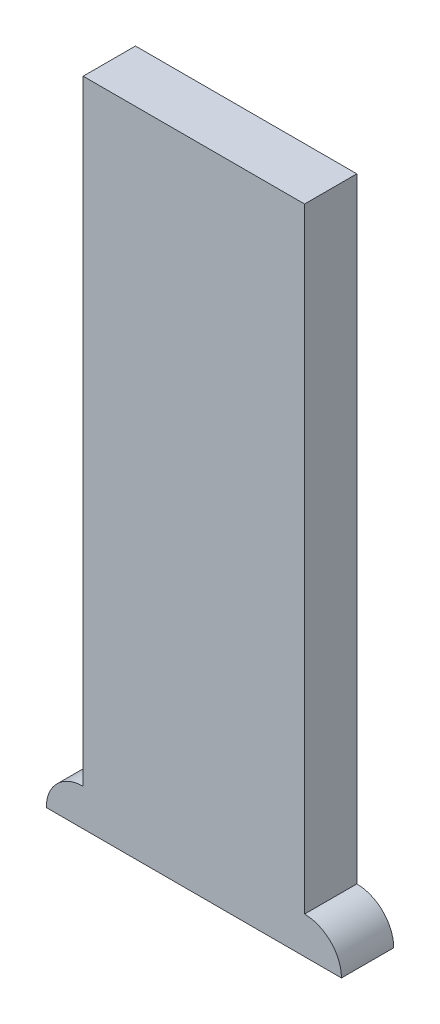
from build123d import *

# Parameters (mm, degrees)
BOSS_EXTRUDE1_DEPTH                             = 8.5
SKETCH5_W                                       = 36
SKETCH5_H                                       = 8.5
BOSS_EXTRUDE2_DEPTH                             = 100
CSK_FOR_M3_FLAT_HEAD_MACHINE_SCREW2_D           = 3.4
CSK_FOR_M3_FLAT_HEAD_MACHINE_SCREW2_DEPTH       = 10
CSK_FOR_M3_FLAT_HEAD_MACHINE_SCREW2_CSINK_D     = 6.3
CSK_FOR_M3_FLAT_HEAD_MACHINE_SCREW2_CSINK_ANGLE = 90
CSK_FOR_M3_FLAT_HEAD_MACHINE_SCREW2_TIP         = 1.021463052
LPATTERN1_COUNT                                 = 12
LPATTERN1_PITCH                                 = 8


with BuildPart() as part:
    # Sketch1 → Boss-Extrude1 (new body)
    with BuildSketch(Plane.XY):
        with BuildLine():
            Line((0, 0), (48, 0))
            ThreePointArc((48, 0), (46.242640687, 4.242640687), (42, 6))
            Line((42, 6), (6, 6))
            ThreePointArc((6, 6), (1.757359313, 4.242640687), (0, 0))
        make_face()
    extrude(amount=BOSS_EXTRUDE1_DEPTH)

    # Sketch5 → Boss-Extrude2 (add)
    with BuildSketch(Plane(origin=(0, 6, 0), x_dir=(1, 0, 0), z_dir=(0, 1, 0))):
        with Locations((24, -4.25)):
            Rectangle(SKETCH5_W, SKETCH5_H)
    extrude(amount=BOSS_EXTRUDE2_DEPTH)

    # Sketch14 → Ø3.0mm Dowel Hole3 (revolve, cut)
    with BuildSketch(Plane(origin=(37, 101, 0), x_dir=(0, 1, 0), z_dir=(1, 0, 0))):
        Polygon((0, 0), (0, 5.901290929), (1.5, 5), (1.5, 0), align=None)
    f_3_0mm_dowel_hole3 = revolve(axis=Axis((37, 101, -6.35), (0, 0, 1)), mode=Mode.SUBTRACT)

    # CSK for M3 Flat Head Machine Screw2
    with Locations(Plane(origin=(0, 0, 0), x_dir=(-1, 0, 0), z_dir=(0, -1, 0))):
        with Locations((-39, -4.25), (-9, -4.25)):
            CounterSinkHole(CSK_FOR_M3_FLAT_HEAD_MACHINE_SCREW2_D / 2, CSK_FOR_M3_FLAT_HEAD_MACHINE_SCREW2_CSINK_D / 2, depth=CSK_FOR_M3_FLAT_HEAD_MACHINE_SCREW2_DEPTH, counter_sink_angle=CSK_FOR_M3_FLAT_HEAD_MACHINE_SCREW2_CSINK_ANGLE)
            with Locations((0, 0, -(CSK_FOR_M3_FLAT_HEAD_MACHINE_SCREW2_DEPTH + CSK_FOR_M3_FLAT_HEAD_MACHINE_SCREW2_TIP / 2))):  # 118° drill point
                Cone(0, CSK_FOR_M3_FLAT_HEAD_MACHINE_SCREW2_D / 2, CSK_FOR_M3_FLAT_HEAD_MACHINE_SCREW2_TIP, mode=Mode.SUBTRACT)

    # Mirror1: Ø3.0mm Dowel Hole3 across plane
    add(f_3_0mm_dowel_hole3.mirror(Plane(origin=(24, 0, 0), x_dir=(0, 0, 1), z_dir=(1, 0, 0))), mode=Mode.SUBTRACT)

    # LPattern1: Ø3.0mm Dowel Hole3 ×12
    with Locations(*[(0, -i * LPATTERN1_PITCH, 0) for i in range(1, LPATTERN1_COUNT)]):
        add(f_3_0mm_dowel_hole3, mode=Mode.SUBTRACT)

    # LPattern1 copy 1 sketch → LPattern1 copy 1 (revolve, cut)
    with BuildSketch(Plane(origin=(11, 93, 0), x_dir=(0, 1, 0), z_dir=(-1, 0, 0))):
        Polygon((0, 0), (0, -5.901290929), (1.5, -5), (1.5, 0), align=None)
    revolve(axis=Axis((11, 93, -6.35), (0, 0, -1)), mode=Mode.SUBTRACT)

    # LPattern1 copy 2 sketch → LPattern1 copy 2 (revolve, cut)
    with BuildSketch(Plane(origin=(11, 85, 0), x_dir=(0, 1, 0), z_dir=(-1, 0, 0))):
        Polygon((0, 0), (0, -5.901290929), (1.5, -5), (1.5, 0), align=None)
    revolve(axis=Axis((11, 85, -6.35), (0, 0, -1)), mode=Mode.SUBTRACT)

    # LPattern1 copy 3 sketch → LPattern1 copy 3 (revolve, cut)
    with BuildSketch(Plane(origin=(11, 77, 0), x_dir=(0, 1, 0), z_dir=(-1, 0, 0))):
        Polygon((0, 0), (0, -5.901290929), (1.5, -5), (1.5, 0), align=None)
    revolve(axis=Axis((11, 77, -6.35), (0, 0, -1)), mode=Mode.SUBTRACT)

    # LPattern1 copy 4 sketch → LPattern1 copy 4 (revolve, cut)
    with BuildSketch(Plane(origin=(11, 69, 0), x_dir=(0, 1, 0), z_dir=(-1, 0, 0))):
        Polygon((0, 0), (0, -5.901290929), (1.5, -5), (1.5, 0), align=None)
    revolve(axis=Axis((11, 69, -6.35), (0, 0, -1)), mode=Mode.SUBTRACT)

    # LPattern1 copy 5 sketch → LPattern1 copy 5 (revolve, cut)
    with BuildSketch(Plane(origin=(11, 61, 0), x_dir=(0, 1, 0), z_dir=(-1, 0, 0))):
        Polygon((0, 0), (0, -5.901290929), (1.5, -5), (1.5, 0), align=None)
    revolve(axis=Axis((11, 61, -6.35), (0, 0, -1)), mode=Mode.SUBTRACT)

    # LPattern1 copy 6 sketch → LPattern1 copy 6 (revolve, cut)
    with BuildSketch(Plane(origin=(11, 53, 0), x_dir=(0, 1, 0), z_dir=(-1, 0, 0))):
        Polygon((0, 0), (0, -5.901290929), (1.5, -5), (1.5, 0), align=None)
    revolve(axis=Axis((11, 53, -6.35), (0, 0, -1)), mode=Mode.SUBTRACT)

    # LPattern1 copy 7 sketch → LPattern1 copy 7 (revolve, cut)
    with BuildSketch(Plane(origin=(11, 45, 0), x_dir=(0, 1, 0), z_dir=(-1, 0, 0))):
        Polygon((0, 0), (0, -5.901290929), (1.5, -5), (1.5, 0), align=None)
    revolve(axis=Axis((11, 45, -6.35), (0, 0, -1)), mode=Mode.SUBTRACT)

    # LPattern1 copy 8 sketch → LPattern1 copy 8 (revolve, cut)
    with BuildSketch(Plane(origin=(11, 37, 0), x_dir=(0, 1, 0), z_dir=(-1, 0, 0))):
        Polygon((0, 0), (0, -5.901290929), (1.5, -5), (1.5, 0), align=None)
    revolve(axis=Axis((11, 37, -6.35), (0, 0, -1)), mode=Mode.SUBTRACT)

    # LPattern1 copy 9 sketch → LPattern1 copy 9 (revolve, cut)
    with BuildSketch(Plane(origin=(11, 29, 0), x_dir=(0, 1, 0), z_dir=(-1, 0, 0))):
        Polygon((0, 0), (0, -5.901290929), (1.5, -5), (1.5, 0), align=None)
    revolve(axis=Axis((11, 29, -6.35), (0, 0, -1)), mode=Mode.SUBTRACT)

    # LPattern1 copy 10 sketch → LPattern1 copy 10 (revolve, cut)
    with BuildSketch(Plane(origin=(11, 21, 0), x_dir=(0, 1, 0), z_dir=(-1, 0, 0))):
        Polygon((0, 0), (0, -5.901290929), (1.5, -5), (1.5, 0), align=None)
    revolve(axis=Axis((11, 21, -6.35), (0, 0, -1)), mode=Mode.SUBTRACT)

    # LPattern1 copy 11 sketch → LPattern1 copy 11 (revolve, cut)
    with BuildSketch(Plane(origin=(11, 13, 0), x_dir=(0, 1, 0), z_dir=(-1, 0, 0))):
        Polygon((0, 0), (0, -5.901290929), (1.5, -5), (1.5, 0), align=None)
    revolve(axis=Axis((11, 13, -6.35), (0, 0, -1)), mode=Mode.SUBTRACT)


solid = part.part
